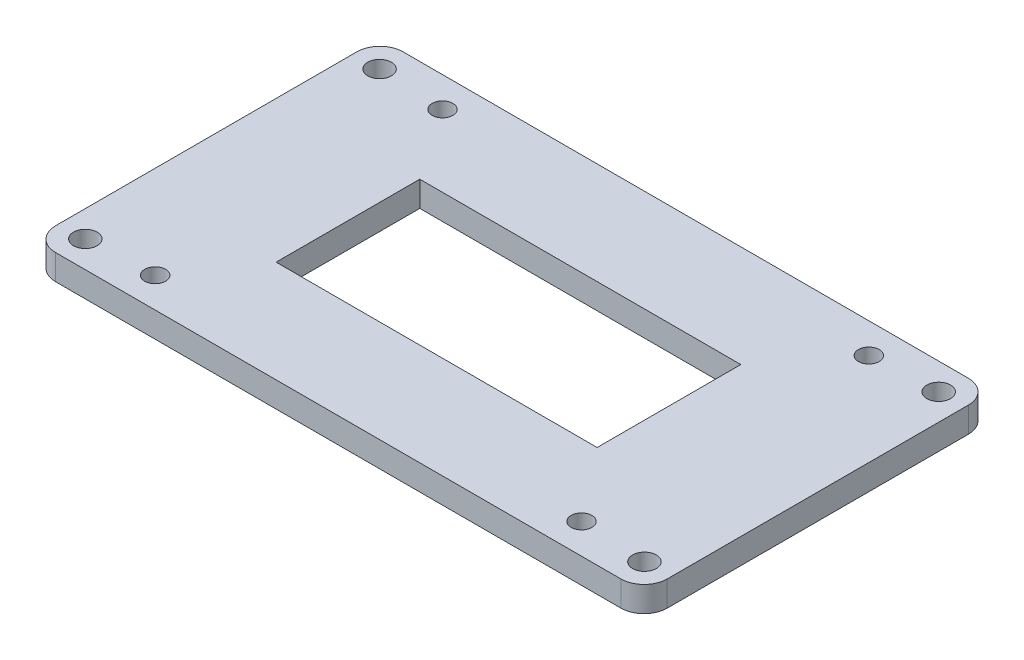
from build123d import *

# Parameters (mm, degrees)
SKETCH2_W              = 132
SKETCH2_H              = 75
BOSS_EXTRUDE1_DEPTH    = 5.461
F_8_CLEARANCE_HOLE1_D  = 4.4958
F_10_CLEARANCE_HOLE1_D = 5.1054
FILLET1_R              = 5
SKETCH7_W              = 69.27
SKETCH7_H              = 31
CUT_EXTRUDE1_DEPTH     = 6.461


with BuildPart() as part:
    # Sketch2 → Boss-Extrude1 (new body)
    with BuildSketch(Plane(origin=(0, 0, 0), x_dir=(1, 0, 0), z_dir=(0, 1, 0))):
        Rectangle(SKETCH2_W, SKETCH2_H)
    extrude(amount=BOSS_EXTRUDE1_DEPTH)

    # #8 Clearance Hole1 (through all)
    with Locations(Plane(origin=(0, 5.461, 0), x_dir=(1, 0, 0), z_dir=(0, 1, 0))):
        with Locations((46, -31), (-46, 31), (-46, -31), (46, 31)):
            Hole(F_8_CLEARANCE_HOLE1_D / 2)

    # #10 Clearance Hole1 (through all)
    with Locations(Plane(origin=(0, 5.461, 0), x_dir=(1, 0, 0), z_dir=(0, 1, 0))):
        with Locations((60.325, -31.75), (-60.325, 31.75), (-60.325, -31.75), (60.325, 31.75)):
            Hole(F_10_CLEARANCE_HOLE1_D / 2)

    # Fillet1
    fillet1_edges = [part.edges().sort_by_distance(p)[0] for p in [
        (66, 2.7305, 37.5),
        (-66, 2.7305, 37.5),
        (-66, 2.7305, -37.5),
        (66, 2.7305, -37.5),
    ]]
    fillet(fillet1_edges, radius=FILLET1_R)

    # Sketch7 → Cut-Extrude1 (cut, through all)
    with BuildSketch(Plane(origin=(0, 5.461, 0), x_dir=(1, 0, 0), z_dir=(0, 1, 0))):
        with Locations((-0.765, 0)):
            Rectangle(SKETCH7_W, SKETCH7_H)
    extrude(amount=-CUT_EXTRUDE1_DEPTH, mode=Mode.SUBTRACT)


solid = part.part
